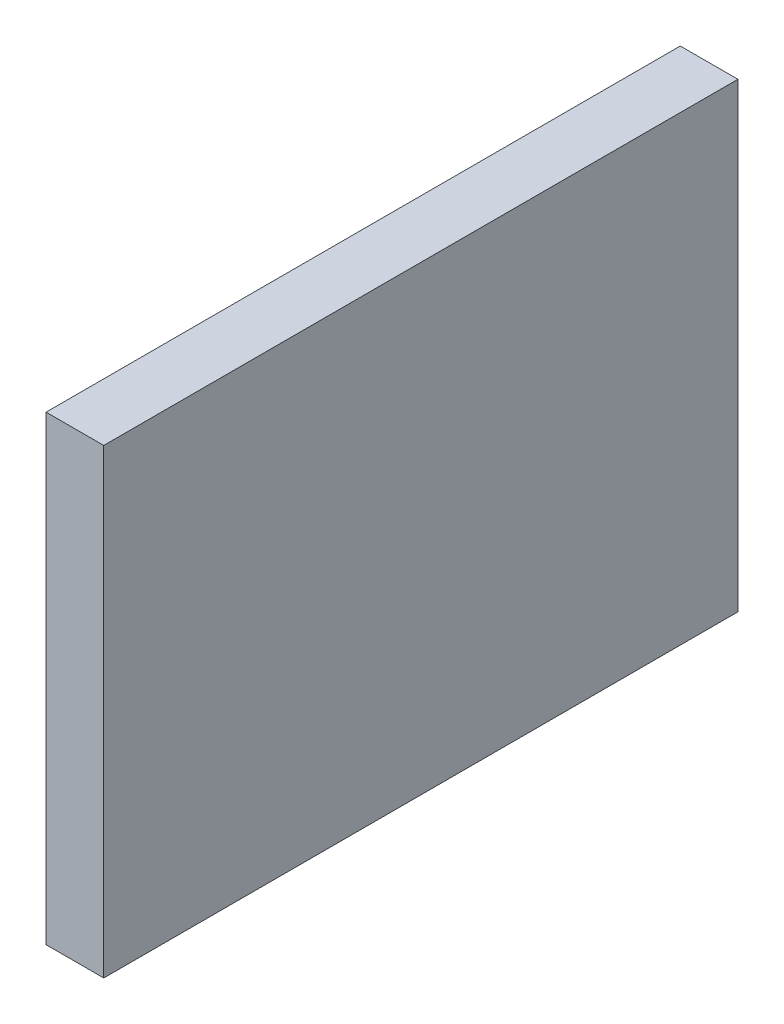
from build123d import *

# Parameters (mm, degrees)
SKETCH2_W           = 25.4
SKETCH2_H           = 203.2
BOSS_EXTRUDE1_DEPTH = 279.4


with BuildPart() as part:
    # Sketch2 → Boss-Extrude1 (new body)
    with BuildSketch(Plane.XY):
        with Locations((932.09999, 661.925305148)):
            Rectangle(SKETCH2_W, SKETCH2_H)
    extrude(amount=BOSS_EXTRUDE1_DEPTH)


solid = part.part
